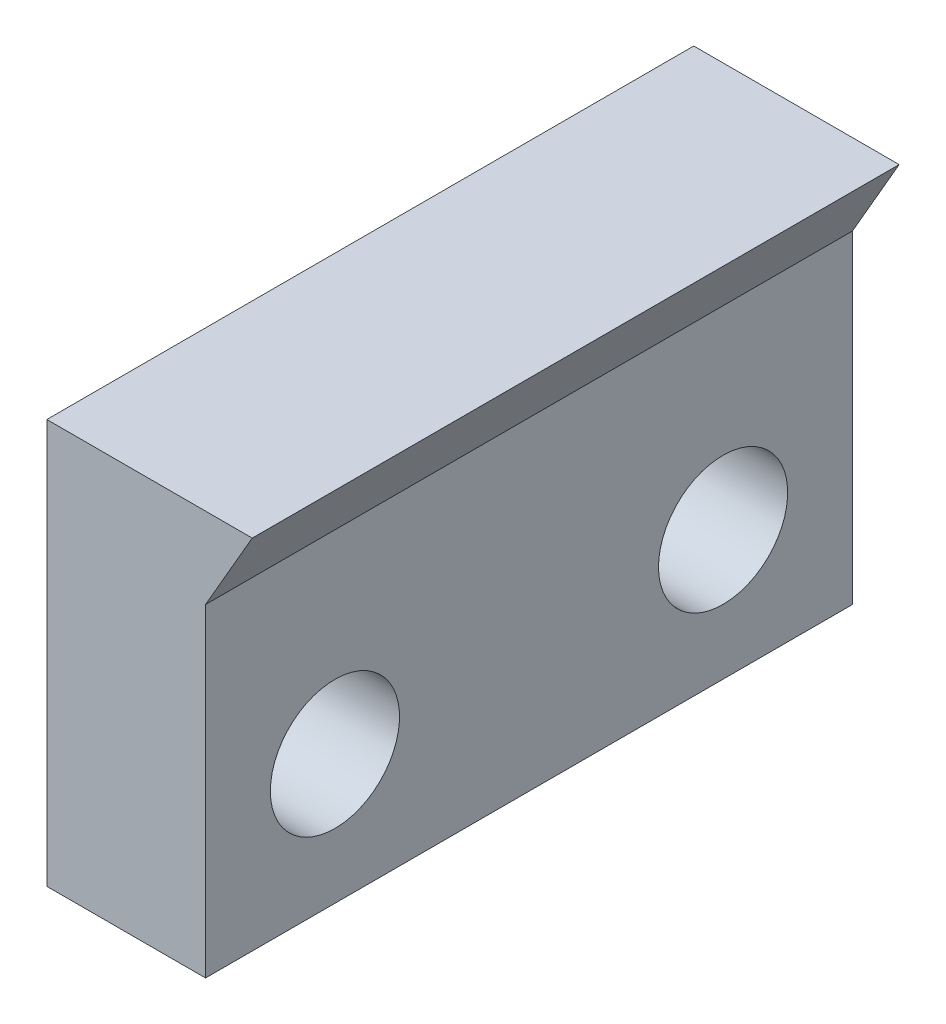
from build123d import *

# Parameters (mm, degrees)
BOSS_EXTRUDE1_DEPTH = 20
SKETCH4_R           = 3.99415
CUT_EXTRUDE1_DEPTH  = 13.7


with BuildPart() as part:
    # Sketch2 → Boss-Extrude1 (new body, symmetric)
    with BuildSketch(Plane.XY):
        Polygon((0, 0), (-9.813248654, 0), (-9.813248654, 25), (2.886751346, 25), (0, 20), align=None)
    extrude(amount=BOSS_EXTRUDE1_DEPTH, both=True)

    # Sketch4 → Cut-Extrude1 (cut, through all)
    with BuildSketch(Plane.ZY.offset(9.813248654)):
        with Locations((-12, 8)):
            Circle(SKETCH4_R)
    cut_extrude1 = extrude(amount=-CUT_EXTRUDE1_DEPTH, mode=Mode.SUBTRACT)

    # Mirror1: Cut-Extrude1 across plane
    add(cut_extrude1.mirror(Plane.XY), mode=Mode.SUBTRACT)


solid = part.part
